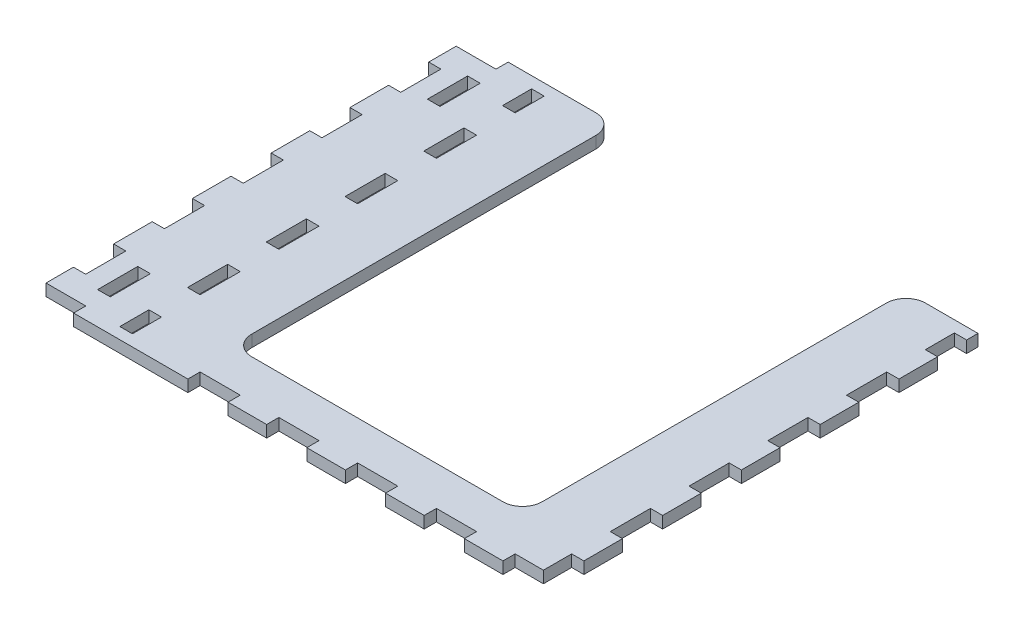
from build123d import *

# Parameters (mm, degrees)
BOSS_EXTRUDE1_DEPTH = 3
SKETCH3_W           = 10.2
SKETCH3_H           = 3.2
SKETCH3_W_2         = 3.2
SKETCH3_H_2         = 10.2
SKETCH3_H_3         = 7.372217102
CUT_EXTRUDE1_DEPTH  = 4


with BuildPart() as part:
    # Sketch2 → Boss-Extrude1 (new body)
    with BuildSketch(Plane(origin=(0, 0, 0), x_dir=(1, 0, 0), z_dir=(0, 1, 0))):
        with BuildLine():
            Line((-74.222217102, -66.842990858), (55.172217102, -66.842990858))
            Line((55.172217102, -66.842990858), (55.172217102, 43.501443346))
            Line((55.172217102, 43.501443346), (41.872217102, 43.501443346))
            ThreePointArc((41.872217102, 43.501443346), (38.336683196, 42.036977252), (36.872217102, 38.501443346))
            Line((36.872217102, 38.501443346), (36.872217102, -48.842990858))
            ThreePointArc((36.872217102, -48.842990858), (35.407751008, -52.378524764), (31.872217102, -53.842990858))
            Line((31.872217102, -53.842990858), (-31.872217102, -53.842990858))
            ThreePointArc((-31.872217102, -53.842990858), (-35.407751008, -52.378524764), (-36.872217102, -48.842990858))
            Line((-36.872217102, -48.842990858), (-36.872217102, 38.501443346))
            ThreePointArc((-36.872217102, 38.501443346), (-38.336683196, 42.036977252), (-41.872217102, 43.501443346))
            Line((-41.872217102, 43.501443346), (-74.222217102, 43.501443346))
            Line((-74.222217102, 43.501443346), (-74.222217102, -66.842990858))
        make_face()
    extrude(amount=-BOSS_EXTRUDE1_DEPTH)

    # Sketch3 → Cut-Extrude1 (cut, through all)
    with BuildSketch(Plane(origin=(0, 0, 0), x_dir=(1, 0, 0), z_dir=(0, 1, 0))):
        with Locations((-69.222217102, -65.342990858)):
            Rectangle(SKETCH3_W, SKETCH3_H)
        with Locations((-53.672217102, 18.329226244)):
            Rectangle(SKETCH3_W_2, SKETCH3_H_2)
        with Locations((-53.672217102, -1.670773756)):
            Rectangle(SKETCH3_W_2, SKETCH3_H_2)
        with Locations((-30, -65.342990858)):
            Rectangle(SKETCH3_W, SKETCH3_H)
        with Locations((-10, -65.342990858)):
            Rectangle(SKETCH3_W, SKETCH3_H)
        with Locations((-53.672217102, 36.915334795)):
            Rectangle(SKETCH3_W_2, SKETCH3_H_3)
        with Locations((30, -65.342990858)):
            Rectangle(SKETCH3_W, SKETCH3_H)
        with Locations((-53.672217102, -41.670773756)):
            Rectangle(SKETCH3_W_2, SKETCH3_H_2)
        with Locations((-53.672217102, -21.670773756)):
            Rectangle(SKETCH3_W_2, SKETCH3_H_2)
        with Locations((-53.672217102, -60.256882307)):
            Rectangle(SKETCH3_W_2, SKETCH3_H_3)
        Polygon((52.072217102, -56.570773756), (52.072217102, -63.742990858), (44.9, -63.742990858), (44.9, -66.942990858), (55.272217102, -66.942990858), (55.272217102, -56.570773756), align=None)
        with Locations((53.672217102, -21.670773756)):
            Rectangle(SKETCH3_W_2, SKETCH3_H_2)
        with Locations((53.672217102, -41.670773756)):
            Rectangle(SKETCH3_W_2, SKETCH3_H_2)
        with Locations((10, -65.342990858)):
            Rectangle(SKETCH3_W, SKETCH3_H)
        with Locations((53.672217102, 18.329226244)):
            Rectangle(SKETCH3_W_2, SKETCH3_H_2)
        with Locations((53.672217102, -1.670773756)):
            Rectangle(SKETCH3_W_2, SKETCH3_H_2)
        with Locations((53.672217102, 36.915334795)):
            Rectangle(SKETCH3_W_2, SKETCH3_H_3)
        with Locations((-72.722217102, 28.329226244)):
            Rectangle(SKETCH3_W_2, SKETCH3_H_2)
        with Locations((-72.722217102, 8.329226244)):
            Rectangle(SKETCH3_W_2, SKETCH3_H_2)
        with Locations((-72.722217102, -11.670773756)):
            Rectangle(SKETCH3_W_2, SKETCH3_H_2)
        with Locations((-69.222217102, 42.001443346)):
            Rectangle(SKETCH3_W, SKETCH3_H)
        with Locations((-64.622217102, -53.542990858)):
            Rectangle(SKETCH3_W_2, SKETCH3_H_2)
        with Locations((-64.622217102, 30.201443346)):
            Rectangle(SKETCH3_W_2, SKETCH3_H_2)
        with Locations((-72.722217102, -51.670773756)):
            Rectangle(SKETCH3_W_2, SKETCH3_H_2)
        with Locations((-72.722217102, -31.670773756)):
            Rectangle(SKETCH3_W_2, SKETCH3_H_2)
    extrude(amount=-CUT_EXTRUDE1_DEPTH, mode=Mode.SUBTRACT)


solid = part.part
